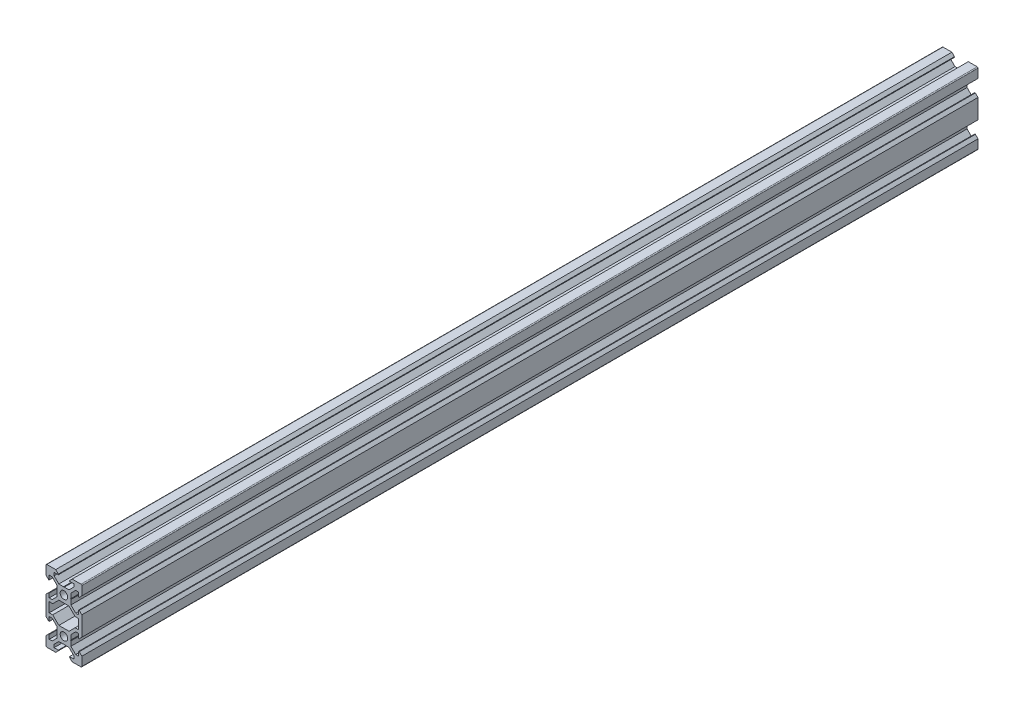
from build123d import *

# Parameters (mm, degrees)
SKETCH1_R           = 2.1
BOSS_EXTRUDE1_DEPTH = 500


with BuildPart() as part:
    # Sketch1 → Boss-Extrude1 (new body)
    with BuildSketch(Plane.XY):
        with BuildLine():
            Line((3.69, 0), (3.9, -0.21))
            Line((3.9, -0.21), (3.9, -2.839339828))
            Line((3.9, -2.839339828), (6.560660172, -5.5))
            Line((6.560660172, -5.5), (8.2, -5.5))
            Line((8.2, -5.5), (8.2, -3.125))
            Line((8.2, -3.125), (8.545, -3.125))
            Line((8.545, -3.125), (10, -4.58))
            Line((10, -4.58), (10, -15.42))
            Line((10, -15.42), (8.545, -16.875))
            Line((8.545, -16.875), (8.2, -16.875))
            Line((8.2, -16.875), (8.2, -14.5))
            Line((8.2, -14.5), (6.560660172, -14.5))
            Line((6.560660172, -14.5), (3.9, -17.160660172))
            Line((3.9, -17.160660172), (3.9, -19.79))
            Line((3.9, -19.79), (3.69, -20))
            Line((3.69, -20), (3.9, -20.21))
            Line((3.9, -20.21), (3.9, -22.839339828))
            Line((3.9, -22.839339828), (6.560660172, -25.5))
            Line((6.560660172, -25.5), (8.2, -25.5))
            Line((8.2, -25.5), (8.2, -23.125))
            Line((8.2, -23.125), (8.545, -23.125))
            Line((8.545, -23.125), (10, -24.58))
            Line((10, -24.58), (10, -29.5))
            ThreePointArc((10, -29.5), (9.853553391, -29.853553391), (9.5, -30))
            Line((9.5, -30), (4.58, -30))
            Line((4.58, -30), (3.125, -28.545))
            Line((3.125, -28.545), (3.125, -28.2))
            Line((3.125, -28.2), (5.5, -28.2))
            Line((5.5, -28.2), (5.5, -26.560660172))
            Line((5.5, -26.560660172), (2.839339828, -23.9))
            Line((2.839339828, -23.9), (0.21, -23.9))
            Line((0.21, -23.9), (0, -23.69))
            Line((0, -23.69), (-0.21, -23.9))
            Line((-0.21, -23.9), (-2.839339828, -23.9))
            Line((-2.839339828, -23.9), (-5.5, -26.560660172))
            Line((-5.5, -26.560660172), (-5.5, -28.2))
            Line((-5.5, -28.2), (-3.125, -28.2))
            Line((-3.125, -28.2), (-3.125, -28.545))
            Line((-3.125, -28.545), (-4.58, -30))
            Line((-4.58, -30), (-9.5, -30))
            ThreePointArc((-9.5, -30), (-9.853553391, -29.853553391), (-10, -29.5))
            Line((-10, -29.5), (-10, -24.58))
            Line((-10, -24.58), (-8.545, -23.125))
            Line((-8.545, -23.125), (-8.2, -23.125))
            Line((-8.2, -23.125), (-8.2, -25.5))
            Line((-8.2, -25.5), (-6.560660172, -25.5))
            Line((-6.560660172, -25.5), (-3.9, -22.839339828))
            Line((-3.9, -22.839339828), (-3.9, -20.21))
            Line((-3.9, -20.21), (-3.69, -20))
            Line((-3.69, -20), (-3.9, -19.79))
            Line((-3.9, -19.79), (-3.9, -17.160660172))
            Line((-3.9, -17.160660172), (-6.560660172, -14.5))
            Line((-6.560660172, -14.5), (-8.2, -14.5))
            Line((-8.2, -14.5), (-8.2, -16.875))
            Line((-8.2, -16.875), (-8.545, -16.875))
            Line((-8.545, -16.875), (-10, -15.42))
            Line((-10, -15.42), (-10, -4.58))
            Line((-10, -4.58), (-8.545, -3.125))
            Line((-8.545, -3.125), (-8.2, -3.125))
            Line((-8.2, -3.125), (-8.2, -5.5))
            Line((-8.2, -5.5), (-6.560660172, -5.5))
            Line((-6.560660172, -5.5), (-3.9, -2.839339828))
            Line((-3.9, -2.839339828), (-3.9, -0.21))
            Line((-3.9, -0.21), (-3.69, 0))
            Line((-3.69, 0), (-3.9, 0.21))
            Line((-3.9, 0.21), (-3.9, 2.839339828))
            Line((-3.9, 2.839339828), (-6.560660172, 5.5))
            Line((-6.560660172, 5.5), (-8.2, 5.5))
            Line((-8.2, 5.5), (-8.2, 3.125))
            Line((-8.2, 3.125), (-8.545, 3.125))
            Line((-8.545, 3.125), (-10, 4.58))
            Line((-10, 4.58), (-10, 9.5))
            ThreePointArc((-10, 9.5), (-9.853553391, 9.853553391), (-9.5, 10))
            Line((-9.5, 10), (-4.58, 10))
            Line((-4.58, 10), (-3.125, 8.545))
            Line((-3.125, 8.545), (-3.125, 8.2))
            Line((-3.125, 8.2), (-5.5, 8.2))
            Line((-5.5, 8.2), (-5.5, 6.560660172))
            Line((-5.5, 6.560660172), (-2.839339828, 3.9))
            Line((-2.839339828, 3.9), (-0.21, 3.9))
            Line((-0.21, 3.9), (0, 3.69))
            Line((0, 3.69), (0.21, 3.9))
            Line((0.21, 3.9), (2.839339828, 3.9))
            Line((2.839339828, 3.9), (5.5, 6.560660172))
            Line((5.5, 6.560660172), (5.5, 8.2))
            Line((5.5, 8.2), (3.125, 8.2))
            Line((3.125, 8.2), (3.125, 8.545))
            Line((3.125, 8.545), (4.58, 10))
            Line((4.58, 10), (9.5, 10))
            ThreePointArc((9.5, 10), (9.853553391, 9.853553391), (10, 9.5))
            Line((10, 9.5), (10, 4.58))
            Line((10, 4.58), (8.545, 3.125))
            Line((8.545, 3.125), (8.2, 3.125))
            Line((8.2, 3.125), (8.2, 5.5))
            Line((8.2, 5.5), (6.560660172, 5.5))
            Line((6.560660172, 5.5), (3.9, 2.839339828))
            Line((3.9, 2.839339828), (3.9, 0.21))
            Line((3.9, 0.21), (3.69, 0))
        make_face()
        with Locations((0, -20)):
            Circle(SKETCH1_R, mode=Mode.SUBTRACT)
        Circle(SKETCH1_R, mode=Mode.SUBTRACT)
        Polygon((-8.2, -12.7), (-6.239339828, -12.7), (-2.839339828, -16.1), (2.839339828, -16.1), (6.239339828, -12.7), (8.2, -12.7), (8.2, -7.3), (6.239339828, -7.3), (2.839339828, -3.9), (-2.839339828, -3.9), (-6.239339828, -7.3), (-8.2, -7.3), align=None, mode=Mode.SUBTRACT)
    extrude(amount=BOSS_EXTRUDE1_DEPTH)


solid = part.part
